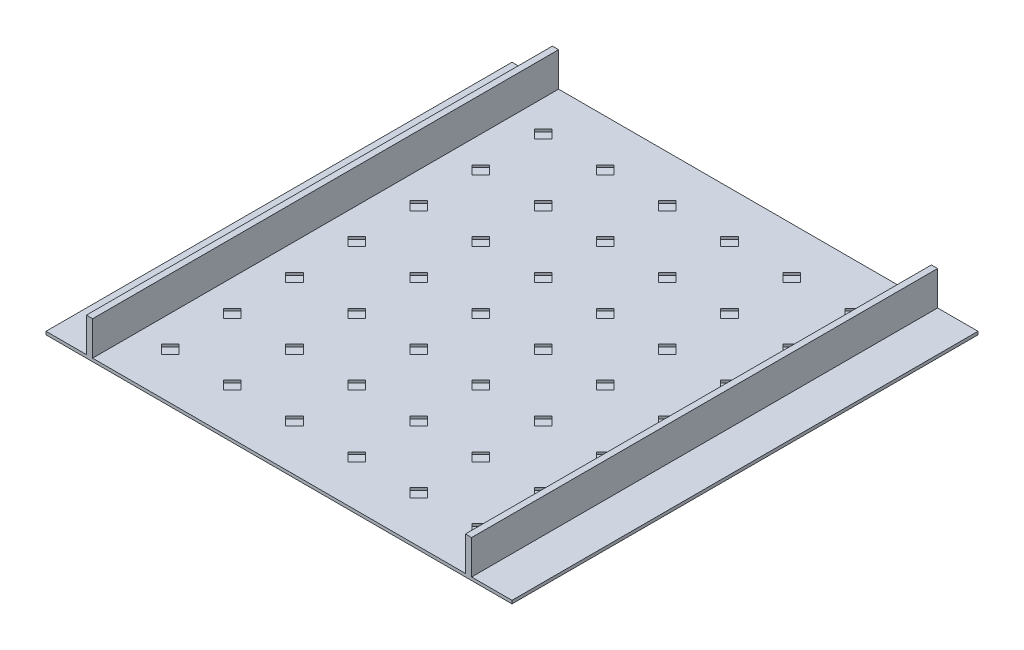
from build123d import *

# Parameters (mm, degrees)
SKETCH2_W           = 1500
SKETCH2_H           = 1500
BOSS_EXTRUDE1_DEPTH = 10
SKETCH3_W           = 20
SKETCH3_H           = 1500
BOSS_EXTRUDE2_DEPTH = 110
CUT_EXTRUDE1_DEPTH  = 8


with BuildPart() as part:
    # Sketch2 → Boss-Extrude1 (new body)
    with BuildSketch(Plane(origin=(0, 0, 0), x_dir=(1, 0, 0), z_dir=(0, 1, 0))):
        Rectangle(SKETCH2_W, SKETCH2_H)
    extrude(amount=BOSS_EXTRUDE1_DEPTH)

    # Sketch3 → Boss-Extrude2 (add)
    with BuildSketch(Plane(origin=(0, 10, 0), x_dir=(1, 0, 0), z_dir=(0, 1, 0))):
        with Locations((-610, 0)):
            Rectangle(SKETCH3_W, SKETCH3_H)
        with Locations((610, 0)):
            Rectangle(SKETCH3_W, SKETCH3_H)
    extrude(amount=BOSS_EXTRUDE2_DEPTH)

    # Sketch4 → Cut-Extrude1 (cut)
    with BuildSketch(Plane(origin=(0, 10, 0), x_dir=(1, 0, 0), z_dir=(0, 1, 0))):
        Polygon((-500, 628.284271247), (-471.715728753, 600), (-500, 571.715728753), (-528.284271247, 600), align=None)
        Polygon((-300, 628.284271247), (-271.715728753, 600), (-300, 571.715728753), (-328.284271247, 600), align=None)
        Polygon((-100, 628.284271247), (-71.715728753, 600), (-100, 571.715728753), (-128.284271247, 600), align=None)
        Polygon((100, 628.284271247), (128.284271247, 600), (100, 571.715728753), (71.715728753, 600), align=None)
        Polygon((300, 628.284271247), (328.284271247, 600), (300, 571.715728753), (271.715728753, 600), align=None)
        Polygon((500, 628.284271247), (528.284271247, 600), (500, 571.715728753), (471.715728753, 600), align=None)
        Polygon((-300, 428.284271247), (-271.715728753, 400), (-300, 371.715728753), (-328.284271247, 400), align=None)
        Polygon((-100, 428.284271247), (-71.715728753, 400), (-100, 371.715728753), (-128.284271247, 400), align=None)
        Polygon((100, 428.284271247), (128.284271247, 400), (100, 371.715728753), (71.715728753, 400), align=None)
        Polygon((300, 428.284271247), (328.284271247, 400), (300, 371.715728753), (271.715728753, 400), align=None)
        Polygon((500, 428.284271247), (528.284271247, 400), (500, 371.715728753), (471.715728753, 400), align=None)
        Polygon((-300, 228.284271247), (-271.715728753, 200), (-300, 171.715728753), (-328.284271247, 200), align=None)
        Polygon((-100, 228.284271247), (-71.715728753, 200), (-100, 171.715728753), (-128.284271247, 200), align=None)
        Polygon((100, 228.284271247), (128.284271247, 200), (100, 171.715728753), (71.715728753, 200), align=None)
        Polygon((300, 228.284271247), (328.284271247, 200), (300, 171.715728753), (271.715728753, 200), align=None)
        Polygon((500, 228.284271247), (528.284271247, 200), (500, 171.715728753), (471.715728753, 200), align=None)
        Polygon((-300, 28.284271247), (-271.715728753, 0), (-300, -28.284271247), (-328.284271247, 0), align=None)
        Polygon((-100, 28.284271247), (-71.715728753, 0), (-100, -28.284271247), (-128.284271247, 0), align=None)
        Polygon((100, 28.284271247), (128.284271247, 0), (100, -28.284271247), (71.715728753, 0), align=None)
        Polygon((300, 28.284271247), (328.284271247, 0), (300, -28.284271247), (271.715728753, 0), align=None)
        Polygon((500, 28.284271247), (528.284271247, 0), (500, -28.284271247), (471.715728753, 0), align=None)
        Polygon((-300, -171.715728753), (-271.715728753, -200), (-300, -228.284271247), (-328.284271247, -200), align=None)
        Polygon((-100, -171.715728753), (-71.715728753, -200), (-100, -228.284271247), (-128.284271247, -200), align=None)
        Polygon((100, -171.715728753), (128.284271247, -200), (100, -228.284271247), (71.715728753, -200), align=None)
        Polygon((300, -171.715728753), (328.284271247, -200), (300, -228.284271247), (271.715728753, -200), align=None)
        Polygon((500, -171.715728753), (528.284271247, -200), (500, -228.284271247), (471.715728753, -200), align=None)
        Polygon((-300, -371.715728753), (-271.715728753, -400), (-300, -428.284271247), (-328.284271247, -400), align=None)
        Polygon((-100, -371.715728753), (-71.715728753, -400), (-100, -428.284271247), (-128.284271247, -400), align=None)
        Polygon((100, -371.715728753), (128.284271247, -400), (100, -428.284271247), (71.715728753, -400), align=None)
        Polygon((300, -371.715728753), (328.284271247, -400), (300, -428.284271247), (271.715728753, -400), align=None)
        Polygon((500, -371.715728753), (528.284271247, -400), (500, -428.284271247), (471.715728753, -400), align=None)
        Polygon((-500, 428.284271247), (-471.715728753, 400), (-500, 371.715728753), (-528.284271247, 400), align=None)
        Polygon((-500, 228.284271247), (-471.715728753, 200), (-500, 171.715728753), (-528.284271247, 200), align=None)
        Polygon((-500, 28.284271247), (-471.715728753, 0), (-500, -28.284271247), (-528.284271247, 0), align=None)
        Polygon((-500, -171.715728753), (-471.715728753, -200), (-500, -228.284271247), (-528.284271247, -200), align=None)
        Polygon((-500, -371.715728753), (-471.715728753, -400), (-500, -428.284271247), (-528.284271247, -400), align=None)
        Polygon((-500, -571.715728753), (-471.715728753, -600), (-500, -628.284271247), (-528.284271247, -600), align=None)
        Polygon((-300, -571.715728753), (-271.715728753, -600), (-300, -628.284271247), (-328.284271247, -600), align=None)
        Polygon((-100, -571.715728753), (-71.715728753, -600), (-100, -628.284271247), (-128.284271247, -600), align=None)
        Polygon((100, -571.715728753), (128.284271247, -600), (100, -628.284271247), (71.715728753, -600), align=None)
        Polygon((300, -571.715728753), (328.284271247, -600), (300, -628.284271247), (271.715728753, -600), align=None)
        Polygon((500, -571.715728753), (528.284271247, -600), (500, -628.284271247), (471.715728753, -600), align=None)
    extrude(amount=-CUT_EXTRUDE1_DEPTH, mode=Mode.SUBTRACT)


solid = part.part
